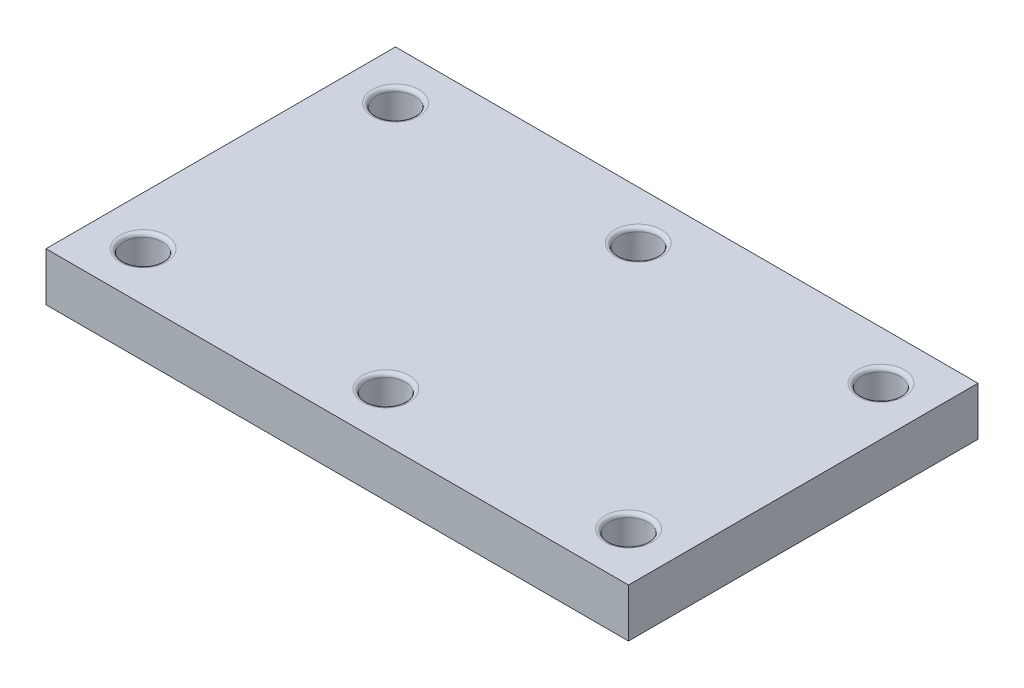
from build123d import *

# Parameters (mm, degrees)
SKETCH1_W           = 300
SKETCH1_H           = 180
BOSS_EXTRUDE1_DEPTH = 25
SKETCH2_R           = 10
CUT_EXTRUDE4_DEPTH  = 212
SKETCH2_5_R         = 10
CUT_EXTRUDE5_DEPTH  = 159
SKETCH2_6_R         = 10
CUT_EXTRUDE6_DEPTH  = 209
SKETCH2_7_R         = 10
CUT_EXTRUDE7_DEPTH  = 305
FILLET1_R           = 2


with BuildPart() as part:
    # Sketch1 → Boss-Extrude1 (new body)
    with BuildSketch(Plane(origin=(0, 0, 0), x_dir=(1, 0, 0), z_dir=(0, 1, 0))):
        Rectangle(SKETCH1_W, SKETCH1_H)
    extrude(amount=BOSS_EXTRUDE1_DEPTH)

    # Sketch2 → Cut-Extrude4 (cut)
    with BuildSketch(Plane(origin=(0, 0, 0), x_dir=(1, 0, 0), z_dir=(0, 1, 0))):
        with Locations((0, 65)):
            Circle(SKETCH2_R)
    extrude(amount=CUT_EXTRUDE4_DEPTH, mode=Mode.SUBTRACT)

    # Sketch2_5 → Cut-Extrude5 (cut)
    with BuildSketch(Plane(origin=(0, 0, 0), x_dir=(1, 0, 0), z_dir=(0, 1, 0))):
        with Locations((-125, 65)):
            Circle(SKETCH2_5_R)
    extrude(amount=CUT_EXTRUDE5_DEPTH, mode=Mode.SUBTRACT)

    # Sketch2_6 → Cut-Extrude6 (cut)
    with BuildSketch(Plane(origin=(0, 0, 0), x_dir=(1, 0, 0), z_dir=(0, 1, 0))):
        with Locations((125, 65)):
            Circle(SKETCH2_6_R)
    extrude(amount=CUT_EXTRUDE6_DEPTH, mode=Mode.SUBTRACT)

    # Sketch2_7 → Cut-Extrude7 (cut)
    with BuildSketch(Plane(origin=(0, 0, 0), x_dir=(1, 0, 0), z_dir=(0, 1, 0))):
        with Locations((125, -65)):
            Circle(SKETCH2_7_R)
        with Locations((0, -65)):
            Circle(SKETCH2_7_R)
        with Locations((-125, -65)):
            Circle(SKETCH2_7_R)
    extrude(amount=CUT_EXTRUDE7_DEPTH, mode=Mode.SUBTRACT)

    # Fillet1
    fillet1_edges = [part.edges().sort_by_distance(p)[0] for p in [
        (-135, 25, -65),
        (-10, 25, -65),
        (115, 25, -65),
        (115, 25, 65),
        (-10, 25, 65),
        (-135, 25, 65),
    ]]
    fillet(fillet1_edges, radius=FILLET1_R)


solid = part.part
